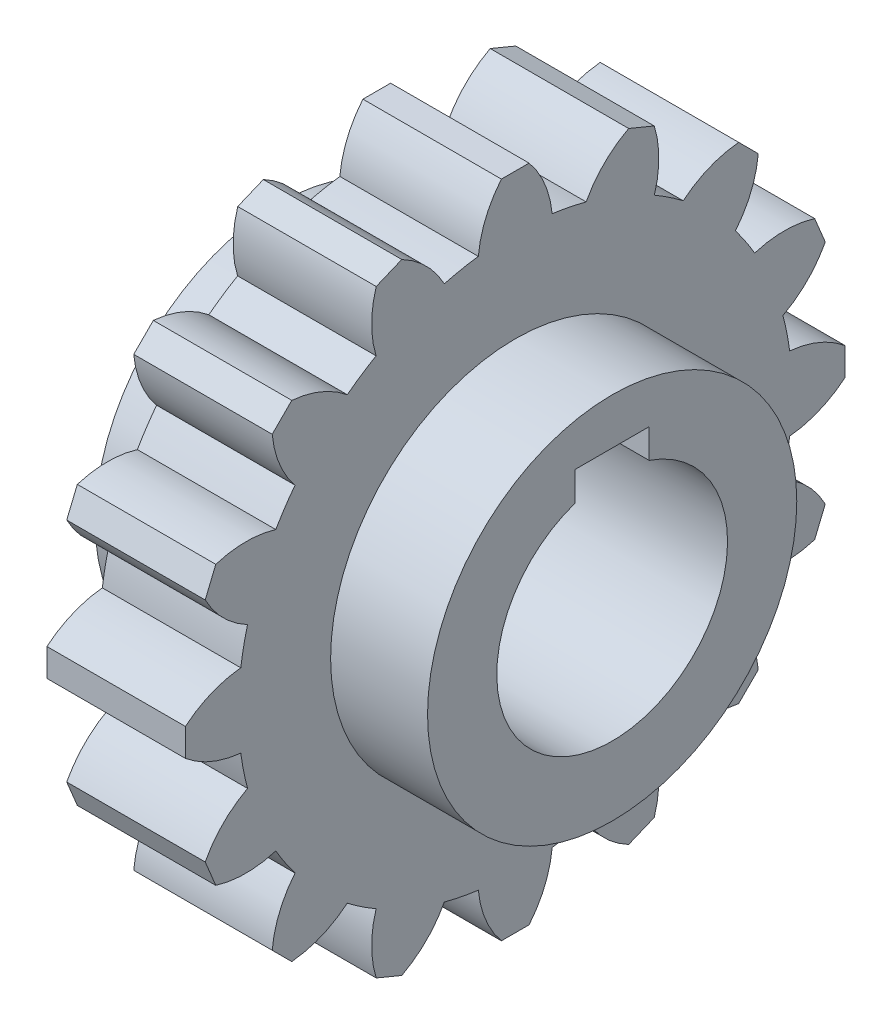
from build123d import *

# Parameters (mm, degrees)
SKETCH1_R           = 30
BOSS_EXTRUDE1_DEPTH = 7.5
BOSS_EXTRUDE2_DEPTH = 15
SKETCH4_R           = 20
BOSS_EXTRUDE3_DEPTH = 18
CUT_EXTRUDE1_DEPTH  = 37
CIRPATTERN1_COUNT   = 16


with BuildPart() as part:
    # Sketch1 → Boss-Extrude1 (new body, symmetric)
    with BuildSketch(Plane(origin=(0, 0, 0), x_dir=(0, 0, -1), z_dir=(1, 0, 0))):
        Circle(SKETCH1_R)
    extrude(amount=BOSS_EXTRUDE1_DEPTH, both=True)

    # Sketch3 → Boss-Extrude2 (add)
    with BuildSketch(Plane(origin=(7.5, 0, 0), x_dir=(0, 0, -1), z_dir=(1, 0, 0))):
        with BuildLine():
            Line((-1.5, 35.732137495), (1.5, 35.732137495))
            ThreePointArc((1.5, 35.732137495), (3.203300204, 32.92101258), (4, 29.732137495))
            ThreePointArc((4, 29.732137495), (0, 30), (-4, 29.732137495))
            ThreePointArc((-4, 29.732137495), (-3.203300204, 32.92101258), (-1.5, 35.732137495))
        make_face()
    boss_extrude2 = extrude(amount=-BOSS_EXTRUDE2_DEPTH)

    # Sketch4 → Boss-Extrude3 (add, symmetric)
    with BuildSketch(Plane(origin=(0, 0, 0), x_dir=(0, 0, -1), z_dir=(1, 0, 0))):
        Circle(SKETCH4_R)
    extrude(amount=BOSS_EXTRUDE3_DEPTH, both=True)

    # Sketch5 → Cut-Extrude1 (cut, through all)
    with BuildSketch(Plane(origin=(18, 0, 0), x_dir=(0, 0, -1), z_dir=(1, 0, 0))):
        with BuildLine():
            Line((-4, 15), (4, 15))
            Line((4, 15), (4, 11.842719282))
            ThreePointArc((4, 11.842719282), (0, -12.5), (-4, 11.842719282))
            Line((-4, 11.842719282), (-4, 15))
        make_face()
    extrude(amount=-CUT_EXTRUDE1_DEPTH, mode=Mode.SUBTRACT)

    # CirPattern1: Boss-Extrude2 ×16 about axis
    cirpattern1_axis = Axis((0, 0, 0), (1, 0, 0))
    for i in range(1, CIRPATTERN1_COUNT):
        add(boss_extrude2.rotate(cirpattern1_axis, i * 360 / CIRPATTERN1_COUNT))


solid = part.part
